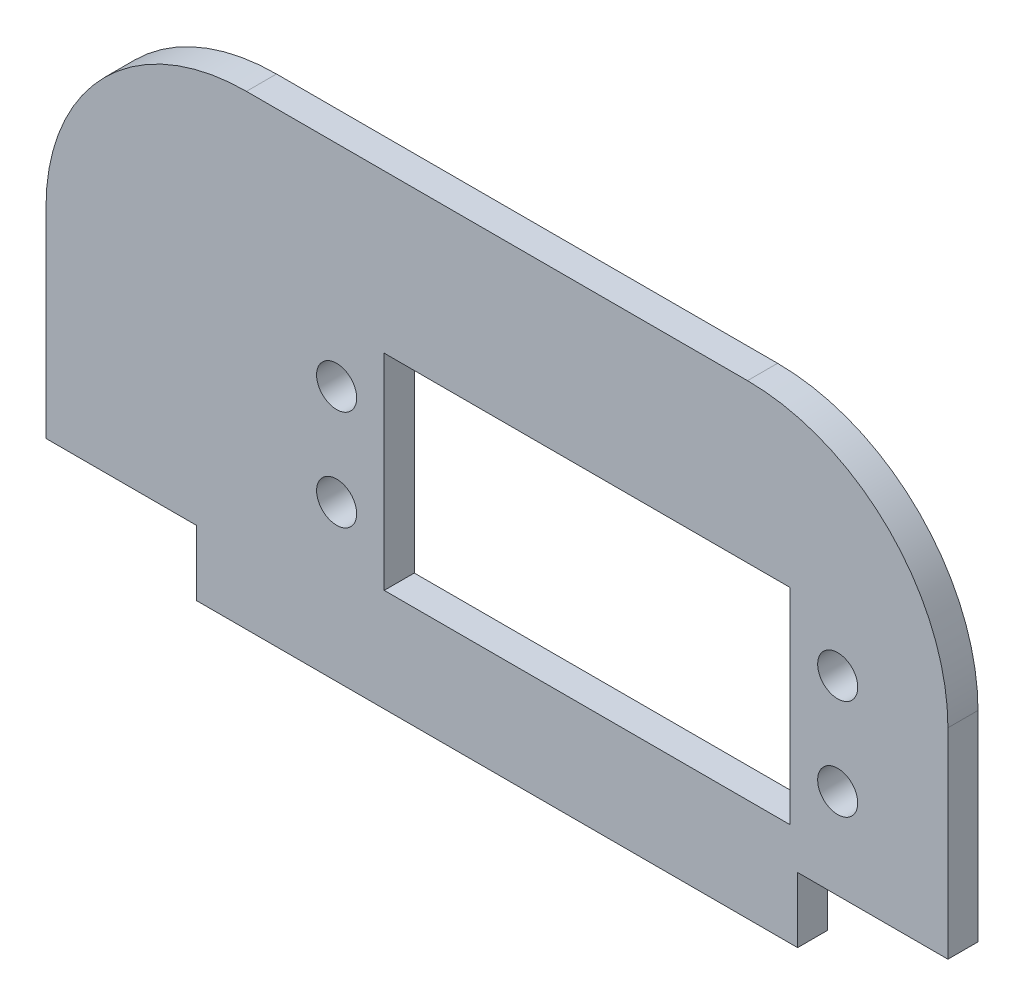
from build123d import *

# Parameters (mm, degrees)
SALIENTE_EXTRUIR1_DEPTH = 3
CORTAR_EXTRUIR1_REACH   = 5
CROQUIS2_W              = 40.5
CROQUIS2_H              = 20.5
REDONDEO1_R             = 20
CORTAR_EXTRUIR2_REACH   = 5
CROQUIS3_R              = 2


with BuildPart() as part:
    # Croquis1 → Saliente-Extruir1 (new body)
    with BuildSketch(Plane.XY):
        Polygon((-45, -20), (-30, -20), (-30, -26.5), (30, -26.5), (30, -20), (45, -20), (45, 20), (-45, 20), align=None)
    extrude(amount=SALIENTE_EXTRUIR1_DEPTH)

    # Croquis2 → Cortar-Extruir1 (cut, up to next)
    with BuildSketch(Plane.XY.offset(3), mode=Mode.PRIVATE) as cortar_extruir1_sk1:
        with Locations((9, -6)):
            Rectangle(CROQUIS2_W, CROQUIS2_H)
    cortar_extruir1_tool1 = extrude(cortar_extruir1_sk1.sketch, amount=-CORTAR_EXTRUIR1_REACH, mode=Mode.PRIVATE) & part.part
    add(cortar_extruir1_tool1.solids().sort_by_distance((9, -6, 3))[0], mode=Mode.SUBTRACT)

    # Redondeo1
    redondeo1_edges = [part.edges().sort_by_distance(p)[0] for p in [
        (-45, 20, 1.5),
        (45, 20, 1.5),
    ]]
    fillet(redondeo1_edges, radius=REDONDEO1_R)

    # Croquis3 → Cortar-Extruir2 (cut, up to next)
    with BuildSketch(Plane.XY.offset(3), mode=Mode.PRIVATE) as cortar_extruir2_sk1:
        with Locations((34, -1)):
            Circle(CROQUIS3_R)
    cortar_extruir2_tool1 = extrude(cortar_extruir2_sk1.sketch, amount=-CORTAR_EXTRUIR2_REACH, mode=Mode.PRIVATE) & part.part
    add(cortar_extruir2_tool1.solids().sort_by_distance((34, -1, 3))[0], mode=Mode.SUBTRACT)
    # Croquis3 → Cortar-Extruir2 (cut, up to next)
    with BuildSketch(Plane.XY.offset(3), mode=Mode.PRIVATE) as cortar_extruir2_sk2:
        with Locations((-16, -1)):
            Circle(CROQUIS3_R)
    cortar_extruir2_tool2 = extrude(cortar_extruir2_sk2.sketch, amount=-CORTAR_EXTRUIR2_REACH, mode=Mode.PRIVATE) & part.part
    add(cortar_extruir2_tool2.solids().sort_by_distance((-16, -1, 3))[0], mode=Mode.SUBTRACT)
    # Croquis3 → Cortar-Extruir2 (cut, up to next)
    with BuildSketch(Plane.XY.offset(3), mode=Mode.PRIVATE) as cortar_extruir2_sk3:
        with Locations((34, -11)):
            Circle(CROQUIS3_R)
    cortar_extruir2_tool3 = extrude(cortar_extruir2_sk3.sketch, amount=-CORTAR_EXTRUIR2_REACH, mode=Mode.PRIVATE) & part.part
    add(cortar_extruir2_tool3.solids().sort_by_distance((34, -11, 3))[0], mode=Mode.SUBTRACT)
    # Croquis3 → Cortar-Extruir2 (cut, up to next)
    with BuildSketch(Plane.XY.offset(3), mode=Mode.PRIVATE) as cortar_extruir2_sk4:
        with Locations((-16, -11)):
            Circle(CROQUIS3_R)
    cortar_extruir2_tool4 = extrude(cortar_extruir2_sk4.sketch, amount=-CORTAR_EXTRUIR2_REACH, mode=Mode.PRIVATE) & part.part
    add(cortar_extruir2_tool4.solids().sort_by_distance((-16, -11, 3))[0], mode=Mode.SUBTRACT)


solid = part.part
